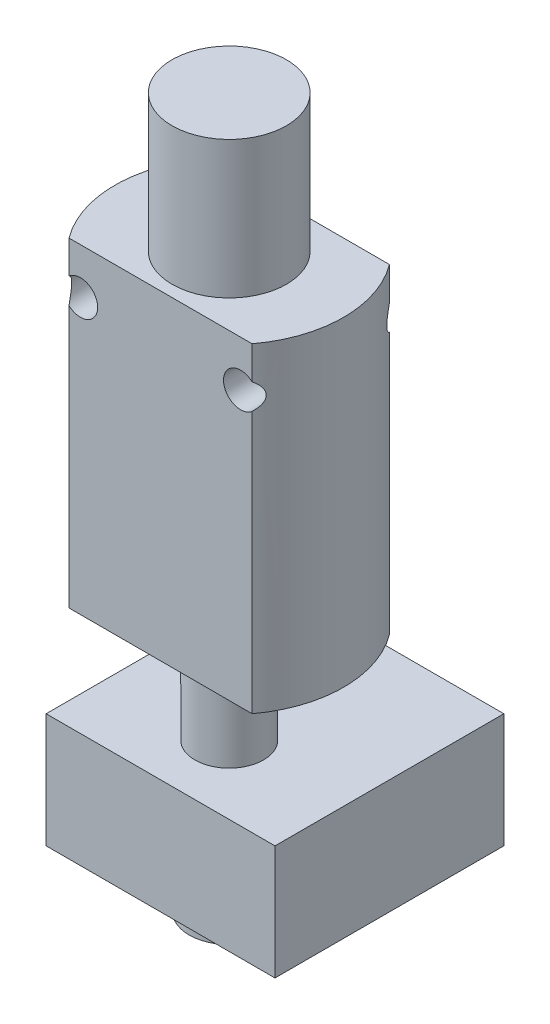
from build123d import *

# Parameters (mm, degrees)
ESBO_O1_W                = 20
ESBO_O1_H                = 28
ESBO_O1_R                = 1.5
RESSALTO_EXTRUS_O1_DEPTH = 6
ESBO_O2_W                = 5
ESBO_O2_H                = 12
RESSALTO_EXTRUS_O2_START = -33
ESBO_O3_W                = 20
ESBO_O3_H                = 20
RESSALTO_EXTRUS_O2_DEPTH = 10
CORTE_EXTRUS_O1_DEPTH    = 28


with BuildPart() as part:
    # Esboço1 → Ressalto-extrusão1 (new body, symmetric)
    with BuildSketch(Plane.XY):
        Rectangle(ESBO_O1_W, ESBO_O1_H)
        with Locations((-7, 10)):
            Circle(ESBO_O1_R, mode=Mode.SUBTRACT)
        with Locations((7, 10)):
            Circle(ESBO_O1_R, mode=Mode.SUBTRACT)
    extrude(amount=RESSALTO_EXTRUS_O1_DEPTH, both=True)

    # Esboço2 → Revolução1 (revolve)
    with BuildSketch(Plane.XY):
        Polygon((3, -33), (3, -23), (3, -14), (0, -14), (0, -38), (0.75, -38), (3.5, -36), (3.5, -33), align=None)
        with Locations((2.5, 20)):
            Rectangle(ESBO_O2_W, ESBO_O2_H)
    revolve(axis=Axis((0, 0, 0), (0, -1, 0)))

    # Esboço3 → Ressalto-extrusão2 (add)
    with BuildSketch(Plane(origin=(0, 0, 0), x_dir=(1, 0, 0), z_dir=(0, 1, 0)).offset(RESSALTO_EXTRUS_O2_START)):
        with Locations((0, 4)):
            Rectangle(ESBO_O3_W, ESBO_O3_H)
    extrude(amount=RESSALTO_EXTRUS_O2_DEPTH)

    # Esboço4 → Corte-extrusão1 (cut)
    with BuildSketch(Plane(origin=(0, 14, 0), x_dir=(1, 0, 0), z_dir=(0, 1, 0))):
        with BuildLine():
            ThreePointArc((-10, 0), (-9.486832981, 3.16227766), (-8, 6))
            Line((-8, 6), (-10, 6))
            Line((-10, 6), (-10, 0))
        make_face()
        with BuildLine():
            ThreePointArc((-8, -6), (-9.486832981, -3.16227766), (-10, 0))
            Line((-10, 0), (-10, -6))
            Line((-10, -6), (-8, -6))
        make_face()
        with BuildLine():
            Line((10, -6), (10, 0))
            ThreePointArc((10, 0), (9.486832981, -3.16227766), (8, -6))
            Line((8, -6), (10, -6))
        make_face()
        with BuildLine():
            Line((10, 6), (8, 6))
            ThreePointArc((8, 6), (9.486832981, 3.16227766), (10, 0))
            Line((10, 0), (10, 6))
        make_face()
    extrude(amount=-CORTE_EXTRUS_O1_DEPTH, mode=Mode.SUBTRACT)


solid = part.part
